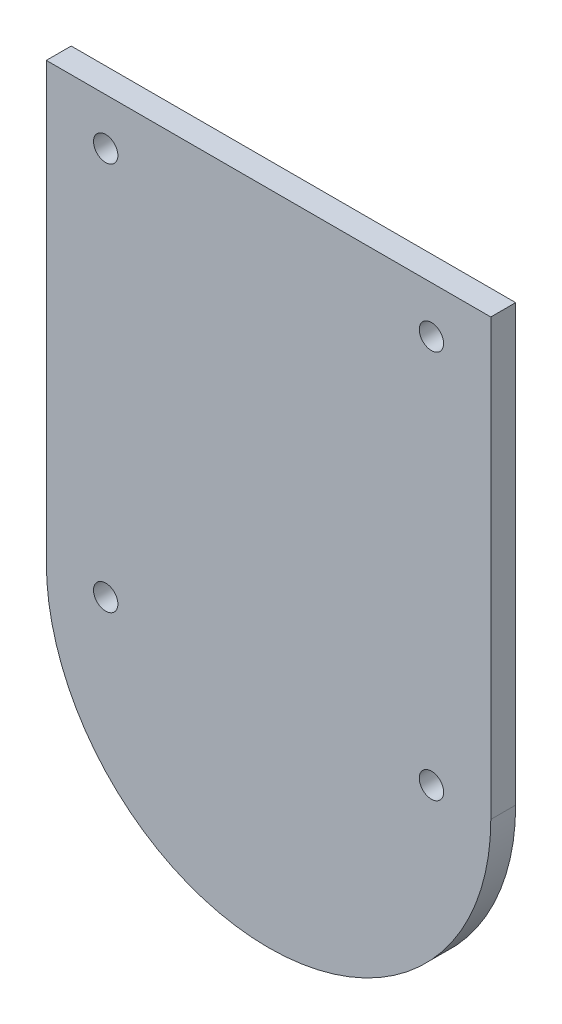
from build123d import *

# Parameters (mm, degrees)
MODEL_R             = 0.7834936
MODEL_R_2           = 6.5
MODEL_W             = 10.5
MODEL_H             = 3
MODEL_H_2           = 4
MODEL_R_3           = 1.229367
EXTRUDE_8_DEPTH     = 1.6
CUT_EXTRUDE_1_DEPTH = 10


with BuildPart() as part:
    # Model → 凸台-拉伸8 (new body)
    with BuildSketch(Plane.XY):
        with BuildLine():
            Line((-28.162112801, 27.669809042), (-37.212112801, 27.669809042))
            Line((-37.212112801, 27.669809042), (-37.212112801, -0.330212606))
            ThreePointArc((-37.212112801, -0.330212606), (-22.912101977, -14.630201782), (-8.612112801, -0.330190958))
            Line((-8.612112801, -0.330190958), (-8.612112801, 27.669809042))
            Line((-8.612112801, 27.669809042), (-17.662112801, 27.669809042))
            Line((-17.662112801, 27.669809042), (-17.662112801, 24.669809042))
            Line((-17.662112801, 24.669809042), (-16.932112801, 24.669809042))
            ThreePointArc((-16.932112801, 24.669809042), (-15.87145263, 24.230469214), (-15.432112801, 23.169809042))
            Line((-15.432112801, 23.169809042), (-15.432112801, -0.330190958))
            ThreePointArc((-15.432112801, -0.330190958), (-22.912112801, -7.810190958), (-30.392112801, -0.330190958))
            Line((-30.392112801, -0.330190958), (-30.392112801, 23.169809042))
            ThreePointArc((-30.392112801, 23.169809042), (-29.952772973, 24.230469214), (-28.892112801, 24.669809042))
            Line((-28.892112801, 24.669809042), (-28.162112801, 24.669809042))
            Line((-28.162112801, 24.669809042), (-28.162112801, 27.669809042))
        make_face()
        with Locations((-33.392112801, -0.330190958)):
            Circle(MODEL_R, mode=Mode.SUBTRACT)
        with Locations((-12.432112801, -0.330190958)):
            Circle(MODEL_R, mode=Mode.SUBTRACT)
        with Locations((-33.392112801, 24.669809042)):
            Circle(MODEL_R, mode=Mode.SUBTRACT)
        with Locations((-12.432112801, 24.669809042)):
            Circle(MODEL_R, mode=Mode.SUBTRACT)
        with BuildLine():
            Line((-30.392112801, -0.330190958), (-30.392112801, 23.169809042))
            ThreePointArc((-30.392112801, 23.169809042), (-29.952772973, 24.230469214), (-28.892112801, 24.669809042))
            Line((-28.892112801, 24.669809042), (-16.932112801, 24.669809042))
            ThreePointArc((-16.932112801, 24.669809042), (-15.87145263, 24.230469214), (-15.432112801, 23.169809042))
            Line((-15.432112801, 23.169809042), (-15.432112801, -0.330190958))
            ThreePointArc((-15.432112801, -0.330190958), (-22.912112801, -7.810190958), (-30.392112801, -0.330190958))
        make_face()
        with Locations((-22.912112801, -0.330190958)):
            Circle(MODEL_R_2, mode=Mode.SUBTRACT)
        with Locations((-22.912112801, 26.169809042)):
            Rectangle(MODEL_W, MODEL_H)
        with Locations((-22.912112801, 29.669809042)):
            Rectangle(MODEL_W, MODEL_H_2)
        with Locations((-22.912112801, 29.669809042)):
            Circle(MODEL_R_3, mode=Mode.SUBTRACT)
        with Locations((-22.912112801, 29.669809042)):
            Circle(MODEL_R_3)
        with Locations((-22.912112801, -0.330190958)):
            Circle(MODEL_R_2)
    extrude(amount=EXTRUDE_8_DEPTH)

    # 草图1 → 切除-拉伸1 (cut)
    with BuildSketch(Plane.XY.offset(1.6)):
        Polygon((-28.162112801, 27.669809042), (-17.662112801, 27.669809042), (-17.662112801, 34.986019155), (-28.743542957, 34.986019155), align=None)
    extrude(amount=-CUT_EXTRUDE_1_DEPTH, mode=Mode.SUBTRACT)


solid = part.part
